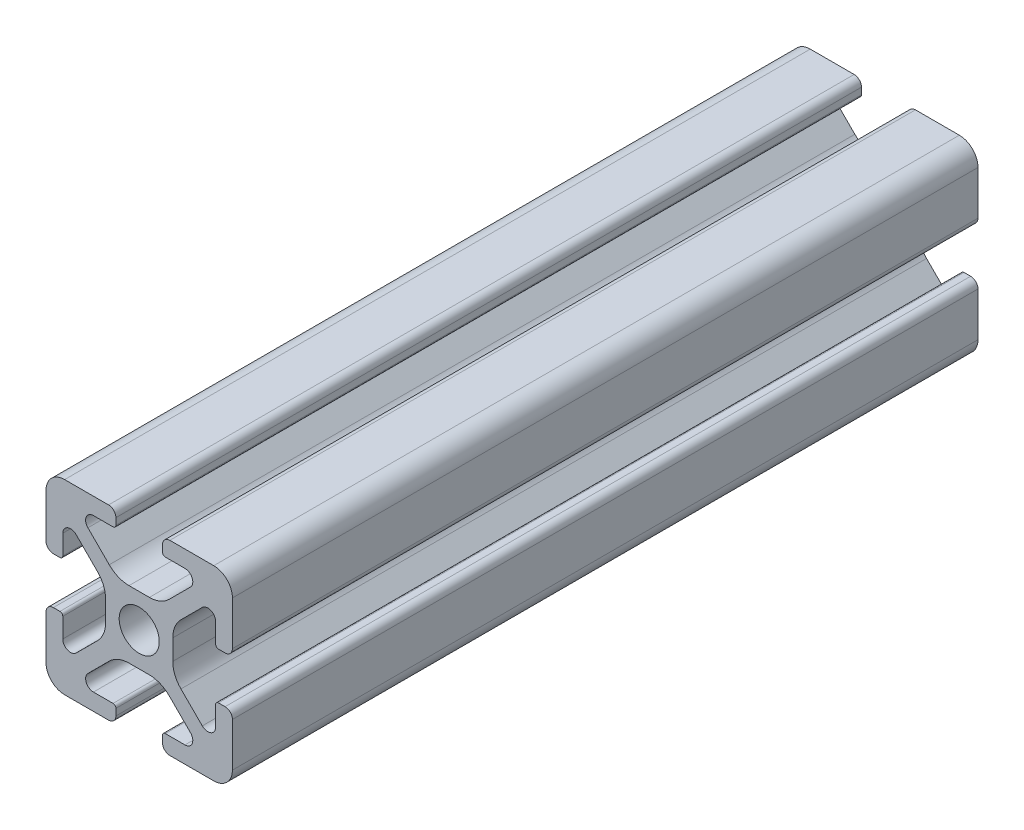
from build123d import *

# Parameters (mm, degrees)
SKETCH3_R                = 2.15
BOSS_EXTRUDE1_DEPTH      = 40
BOSS_EXTRUDE1_DEPTH_BACK = 40


with BuildPart() as part:
    # Sketch3 → Boss-Extrude1 (new body, two sides)
    with BuildSketch(Plane.XY) as boss_extrude1_sk:
        with BuildLine():
            Line((3.2874, 10), (8, 10))
            ThreePointArc((8, 10), (9.414213562, 9.414213562), (10, 8))
            Line((10, 8), (10, 3.2874))
            ThreePointArc((10, 3.2874), (9.76937588, 2.73062412), (9.2126, 2.5))
            Line((9.2126, 2.5), (8.5048, 2.5))
            ThreePointArc((8.5048, 2.5), (8.289273853, 2.589273853), (8.2, 2.8048))
            Line((8.2, 2.8048), (8.2, 4.9118))
            ThreePointArc((8.2, 4.9118), (7.682565253, 5.686195824), (6.769103096, 5.504496904))
            Line((6.769103096, 5.504496904), (4.478679656, 3.214073464))
            ThreePointArc((4.478679656, 3.214073464), (3.828361402, 2.240803418), (3.6, 1.092753121))
            Line((3.6, 1.092753121), (3.6, -1.092753121))
            ThreePointArc((3.6, -1.092753121), (3.828361402, -2.240803418), (4.478679656, -3.214073464))
            Line((4.478679656, -3.214073464), (6.769103096, -5.504496904))
            ThreePointArc((6.769103096, -5.504496904), (7.682565253, -5.686195824), (8.2, -4.9118))
            Line((8.2, -4.9118), (8.2, -2.8048))
            ThreePointArc((8.2, -2.8048), (8.289273853, -2.589273853), (8.5048, -2.5))
            Line((8.5048, -2.5), (9.2126, -2.5))
            ThreePointArc((9.2126, -2.5), (9.76937588, -2.73062412), (10, -3.2874))
            Line((10, -3.2874), (10, -8))
            ThreePointArc((10, -8), (9.414213562, -9.414213562), (8, -10))
            Line((8, -10), (3.2874, -10))
            ThreePointArc((3.2874, -10), (2.73062412, -9.76937588), (2.5, -9.2126))
            Line((2.5, -9.2126), (2.5, -8.5048))
            ThreePointArc((2.5, -8.5048), (2.589273853, -8.289273853), (2.8048, -8.2))
            Line((2.8048, -8.2), (4.9118, -8.2))
            ThreePointArc((4.9118, -8.2), (5.686195824, -7.682565253), (5.504496904, -6.769103096))
            Line((5.504496904, -6.769103096), (3.214073464, -4.478679656))
            ThreePointArc((3.214073464, -4.478679656), (2.240803418, -3.828361402), (1.092753121, -3.6))
            Line((1.092753121, -3.6), (-1.092753121, -3.6))
            ThreePointArc((-1.092753121, -3.6), (-2.240803418, -3.828361402), (-3.214073464, -4.478679656))
            Line((-3.214073464, -4.478679656), (-5.504496904, -6.769103096))
            ThreePointArc((-5.504496904, -6.769103096), (-5.686195824, -7.682565253), (-4.9118, -8.2))
            Line((-4.9118, -8.2), (-2.8048, -8.2))
            ThreePointArc((-2.8048, -8.2), (-2.589273853, -8.289273853), (-2.5, -8.5048))
            Line((-2.5, -8.5048), (-2.5, -9.2126))
            ThreePointArc((-2.5, -9.2126), (-2.73062412, -9.76937588), (-3.2874, -10))
            Line((-3.2874, -10), (-8, -10))
            ThreePointArc((-8, -10), (-9.414213562, -9.414213562), (-10, -8))
            Line((-10, -8), (-10, -3.2874))
            ThreePointArc((-10, -3.2874), (-9.76937588, -2.73062412), (-9.2126, -2.5))
            Line((-9.2126, -2.5), (-8.5048, -2.5))
            ThreePointArc((-8.5048, -2.5), (-8.289273853, -2.589273853), (-8.2, -2.8048))
            Line((-8.2, -2.8048), (-8.2, -4.9118))
            ThreePointArc((-8.2, -4.9118), (-7.682565253, -5.686195824), (-6.769103096, -5.504496904))
            Line((-6.769103096, -5.504496904), (-4.478679656, -3.214073464))
            ThreePointArc((-4.478679656, -3.214073464), (-3.828361402, -2.240803418), (-3.6, -1.092753121))
            Line((-3.6, -1.092753121), (-3.6, 1.092753121))
            ThreePointArc((-3.6, 1.092753121), (-3.828361402, 2.240803418), (-4.478679656, 3.214073464))
            Line((-4.478679656, 3.214073464), (-6.769103096, 5.504496904))
            ThreePointArc((-6.769103096, 5.504496904), (-7.682565253, 5.686195824), (-8.2, 4.9118))
            Line((-8.2, 4.9118), (-8.2, 2.8048))
            ThreePointArc((-8.2, 2.8048), (-8.289273853, 2.589273853), (-8.5048, 2.5))
            Line((-8.5048, 2.5), (-9.2126, 2.5))
            ThreePointArc((-9.2126, 2.5), (-9.76937588, 2.73062412), (-10, 3.2874))
            Line((-10, 3.2874), (-10, 8))
            ThreePointArc((-10, 8), (-9.414213562, 9.414213562), (-8, 10))
            Line((-8, 10), (-3.2874, 10))
            ThreePointArc((-3.2874, 10), (-2.73062412, 9.76937588), (-2.5, 9.2126))
            Line((-2.5, 9.2126), (-2.5, 8.5048))
            ThreePointArc((-2.5, 8.5048), (-2.589273853, 8.289273853), (-2.8048, 8.2))
            Line((-2.8048, 8.2), (-4.9118, 8.2))
            ThreePointArc((-4.9118, 8.2), (-5.686195824, 7.682565253), (-5.504496904, 6.769103096))
            Line((-5.504496904, 6.769103096), (-3.214073464, 4.478679656))
            ThreePointArc((-3.214073464, 4.478679656), (-2.240803418, 3.828361402), (-1.092753121, 3.6))
            Line((-1.092753121, 3.6), (1.092753121, 3.6))
            ThreePointArc((1.092753121, 3.6), (2.240803418, 3.828361402), (3.214073464, 4.478679656))
            Line((3.214073464, 4.478679656), (5.504496904, 6.769103096))
            ThreePointArc((5.504496904, 6.769103096), (5.686195824, 7.682565253), (4.9118, 8.2))
            Line((4.9118, 8.2), (2.8048, 8.2))
            ThreePointArc((2.8048, 8.2), (2.589273853, 8.289273853), (2.5, 8.5048))
            Line((2.5, 8.5048), (2.5, 9.2126))
            ThreePointArc((2.5, 9.2126), (2.73062412, 9.76937588), (3.2874, 10))
        make_face()
        Circle(SKETCH3_R, mode=Mode.SUBTRACT)
    extrude(amount=BOSS_EXTRUDE1_DEPTH)
    extrude(boss_extrude1_sk.sketch, amount=-BOSS_EXTRUDE1_DEPTH_BACK)


solid = part.part
